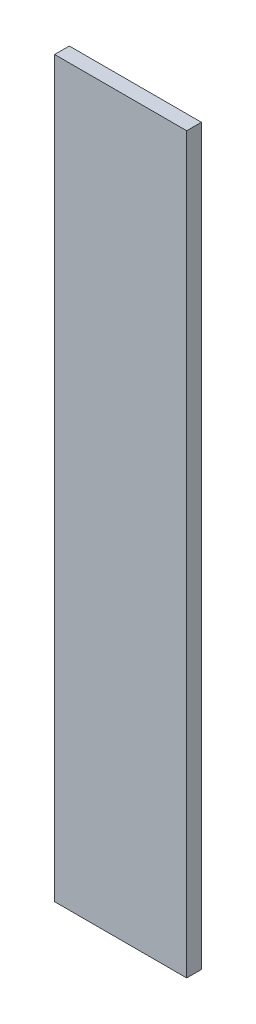
from build123d import *

# Parameters (mm, degrees)
ESQUISSE1_W        = 45
ESQUISSE1_H        = 250
BOSS_EXTRU_1_DEPTH = 5


with BuildPart() as part:
    # Esquisse1 → Boss.-Extru.1 (new body)
    with BuildSketch(Plane.XY):
        with Locations((22.5, 125)):
            Rectangle(ESQUISSE1_W, ESQUISSE1_H)
    extrude(amount=BOSS_EXTRU_1_DEPTH)


solid = part.part
